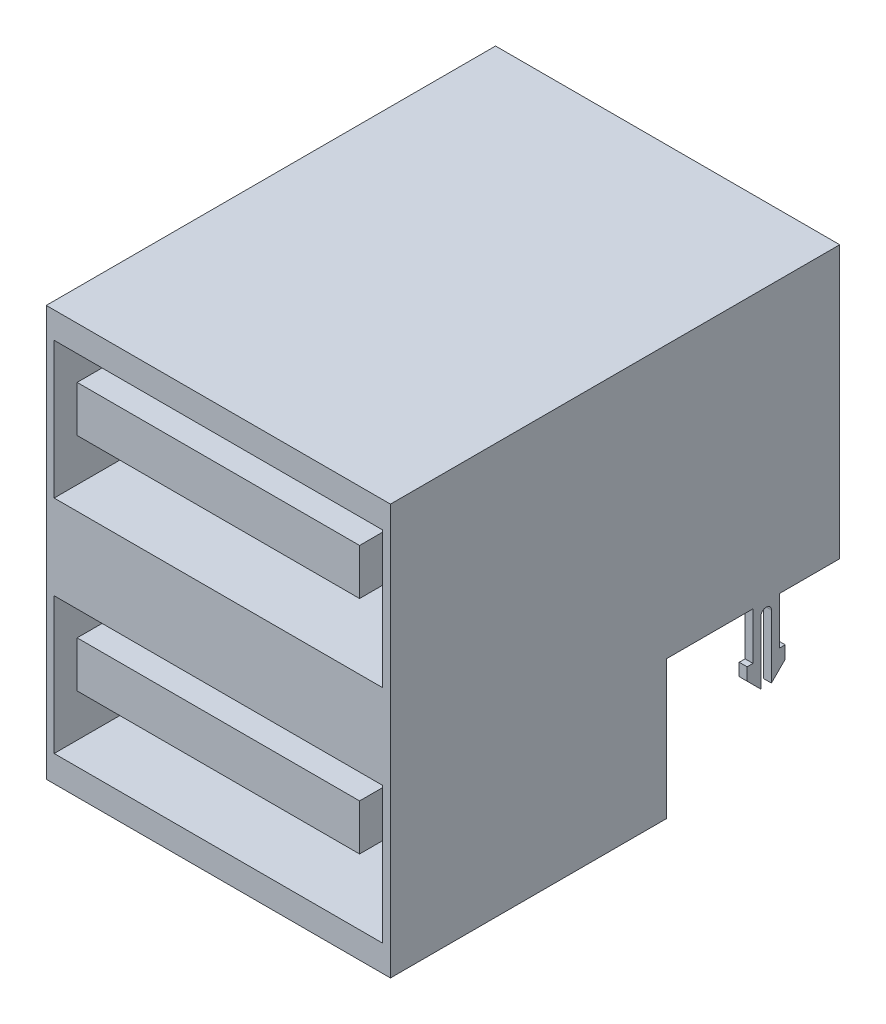
from build123d import *

# Parameters (mm, degrees)
BOSS_EXTRUDE1_DEPTH      = 6.55
BOSS_EXTRUDE1_DEPTH_BACK = 6.55
SKETCH2_W                = 12.5
SKETCH2_H                = 5.2
SKETCH2_W_2              = 10.75
SKETCH2_H_2              = 1.75
CUT_EXTRUDE1_DEPTH       = 9.5
BOSS_EXTRUDE2_DEPTH      = 0.3


with BuildPart() as part:
    # Sketch1 → Boss-Extrude1 (new body, two sides)
    with BuildSketch(Plane(origin=(0, 0, 0), x_dir=(0, 0, -1), z_dir=(1, 0, 0))) as boss_extrude1_sk:
        Polygon((-10.5, 10.35), (6.6, 10.35), (6.6, 0), (0, 0), (0, -5.27), (-10.5, -5.27), align=None)
    extrude(amount=BOSS_EXTRUDE1_DEPTH)
    extrude(boss_extrude1_sk.sketch, amount=-BOSS_EXTRUDE1_DEPTH_BACK)

    # Sketch2 → Cut-Extrude1 (cut)
    with BuildSketch(Plane.XY.offset(10.5)):
        with Locations((0, 6.75)):
            Rectangle(SKETCH2_W, SKETCH2_H)
        with Locations((0, 7.525)):
            Rectangle(SKETCH2_W_2, SKETCH2_H_2, mode=Mode.SUBTRACT)
        with Locations((0, -1.67)):
            Rectangle(SKETCH2_W, SKETCH2_H)
        with Locations((0, -0.895)):
            Rectangle(SKETCH2_W_2, SKETCH2_H_2, mode=Mode.SUBTRACT)
    extrude(amount=-CUT_EXTRUDE1_DEPTH, mode=Mode.SUBTRACT)

    # Sketch3 → Boss-Extrude2 (add)
    with BuildSketch(Plane(origin=(6.55, 0, 0), x_dir=(0, 0, -1), z_dir=(1, 0, 0))):
        with BuildLine():
            Line((3.6, -2.8), (3.075, -2.275))
            Line((3.075, -2.275), (3.075, -1.8))
            Line((3.075, -1.8), (3.3, -1.8))
            Line((3.3, -1.8), (3.3, 0))
            Line((3.3, 0), (4.3, 0))
            Line((4.3, 0), (4.3, -1.8))
            Line((4.3, -1.8), (4.525, -1.8))
            Line((4.525, -1.8), (4.525, -2.275))
            Line((4.525, -2.275), (4, -2.8))
            Line((4, -2.8), (4, -0.395))
            ThreePointArc((4, -0.395), (3.942885822, -0.257114178), (3.805, -0.2))
            Line((3.805, -0.2), (3.795, -0.2))
            ThreePointArc((3.795, -0.2), (3.657114178, -0.257114178), (3.6, -0.395))
            Line((3.6, -0.395), (3.6, -2.8))
        make_face()
    boss_extrude2 = extrude(amount=-BOSS_EXTRUDE2_DEPTH)

    # Mirror1: Boss-Extrude2 across plane
    add(boss_extrude2.mirror(Plane(origin=(0, 0, 0), x_dir=(0, 0, 1), z_dir=(1, 0, 0))))


solid = part.part
